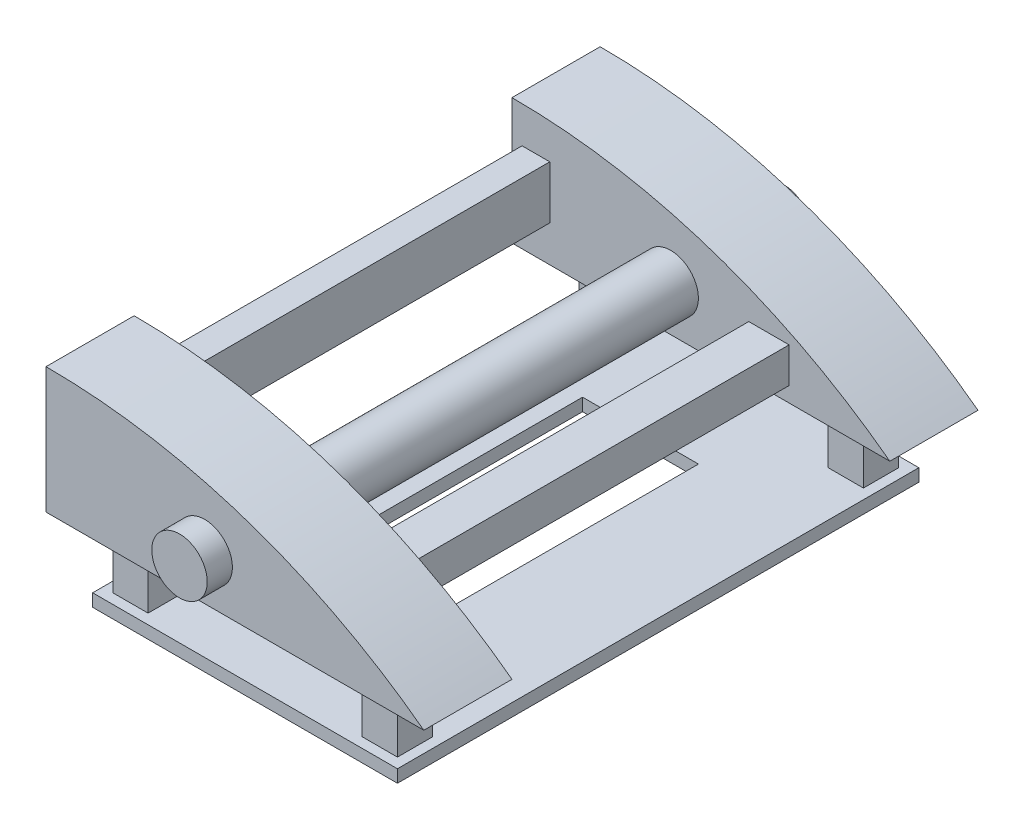
from build123d import *

# Parameters (mm, degrees)
BOSS_EXTRUDE1_DEPTH      = 35
SKETCH2_W                = 11
SKETCH2_H                = 21
BOSS_EXTRUDE3_DEPTH      = 150
BOSS_EXTRUDE4_DEPTH      = 35
SKETCH4_W                = 16
SKETCH4_H                = 14
BOSS_EXTRUDE5_DEPTH      = 150
SKETCH5_W                = 14
SKETCH5_H                = 14
BOSS_EXTRUDE6_DEPTH      = 25
SKETCH6_W                = 121
SKETCH6_H                = 207.00216397
BOSS_EXTRUDE7_DEPTH      = 5
SKETCH7_R                = 11
BOSS_EXTRUDE8_DEPTH      = 10
BOSS_EXTRUDE8_DEPTH_BACK = 230
SKETCH8_W                = 46
SKETCH8_H                = 122
CUT_EXTRUDE1_DEPTH       = 5


with BuildPart() as part:
    # Sketch1 → Boss-Extrude1 (new body)
    with BuildSketch(Plane.XY):
        with BuildLine():
            Line((0, 0), (150, 0))
            ThreePointArc((150, 0), (79.056941504, 37.170824513), (0, 50))
            Line((0, 50), (0, 0))
        make_face()
    extrude(amount=BOSS_EXTRUDE1_DEPTH)

    # Sketch2 → Boss-Extrude3 (add)
    with BuildSketch(Plane.XY.offset(35)):
        with Locations((9.5, 24.924601572)):
            Rectangle(SKETCH2_W, SKETCH2_H)
    extrude(amount=BOSS_EXTRUDE3_DEPTH)

    # Sketch3 → Boss-Extrude4 (add)
    with BuildSketch(Plane.XY.offset(185)):
        with BuildLine():
            Line((150, 0), (0, 0))
            Line((0, 0), (0, 50))
            ThreePointArc((0, 50), (79.056941504, 37.170824513), (150, 0))
        make_face()
    extrude(amount=BOSS_EXTRUDE4_DEPTH)

    # Sketch4 → Boss-Extrude5 (add)
    with BuildSketch(Plane(origin=(0, 0, 185), x_dir=(-1, 0, 0), z_dir=(0, 0, -1))):
        with Locations((-102, 13)):
            Rectangle(SKETCH4_W, SKETCH4_H)
    extrude(amount=BOSS_EXTRUDE5_DEPTH)

    # Sketch5 → Boss-Extrude6 (add)
    with BuildSketch(Plane.XZ):
        with Locations((23, 202.48216397)):
            Rectangle(SKETCH5_W, SKETCH5_H)
        with Locations((23, 17.48)):
            Rectangle(SKETCH5_W, SKETCH5_H)
        with Locations((122, 202.48216397)):
            Rectangle(SKETCH5_W, SKETCH5_H)
        with Locations((122, 17.48)):
            Rectangle(SKETCH5_W, SKETCH5_H)
    extrude(amount=BOSS_EXTRUDE6_DEPTH)

    # Sketch6 → Boss-Extrude7 (add)
    with BuildSketch(Plane(origin=(0, -25, 0), x_dir=(-1, 0, 0), z_dir=(0, -1, 0))):
        with Locations((-72.5, -109.981081985)):
            Rectangle(SKETCH6_W, SKETCH6_H)
    extrude(amount=BOSS_EXTRUDE7_DEPTH)

    # Sketch7 → Boss-Extrude8 (add, two sides)
    with BuildSketch(Plane(origin=(0, 0, 0), x_dir=(-1, 0, 0), z_dir=(0, 0, -1))) as boss_extrude8_sk:
        with Locations((-63, 18)):
            Circle(SKETCH7_R)
    extrude(amount=BOSS_EXTRUDE8_DEPTH)
    extrude(boss_extrude8_sk.sketch, amount=-BOSS_EXTRUDE8_DEPTH_BACK)

    # Sketch8 → Cut-Extrude1 (cut)
    with BuildSketch(Plane.XZ.offset(30)):
        with Locations((65, 109.98216397)):
            Rectangle(SKETCH8_W, SKETCH8_H)
    extrude(amount=-CUT_EXTRUDE1_DEPTH, mode=Mode.SUBTRACT)


solid = part.part
